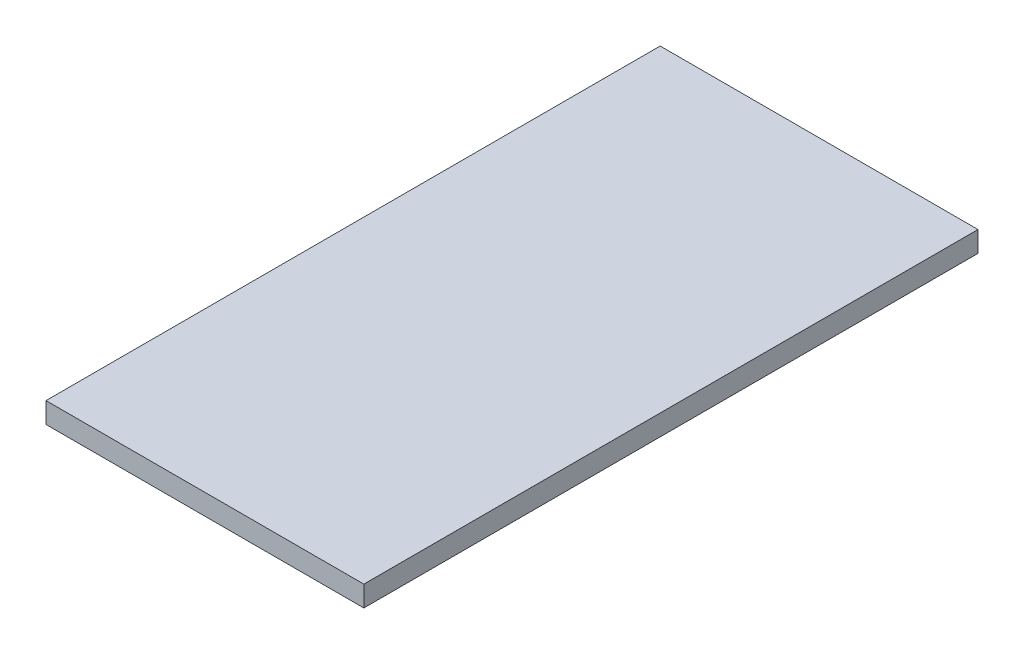
from build123d import *

# Parameters (mm, degrees)
SKETCH1_W           = 97.536
SKETCH1_H           = 188.468
BOSS_EXTRUDE1_DEPTH = 6.35


with BuildPart() as part:
    # Sketch1 → Boss-Extrude1 (new body)
    with BuildSketch(Plane(origin=(0, 0, 0), x_dir=(1, 0, 0), z_dir=(0, 1, 0))):
        with Locations((48.768, 94.234)):
            Rectangle(SKETCH1_W, SKETCH1_H)
    extrude(amount=BOSS_EXTRUDE1_DEPTH)


solid = part.part
